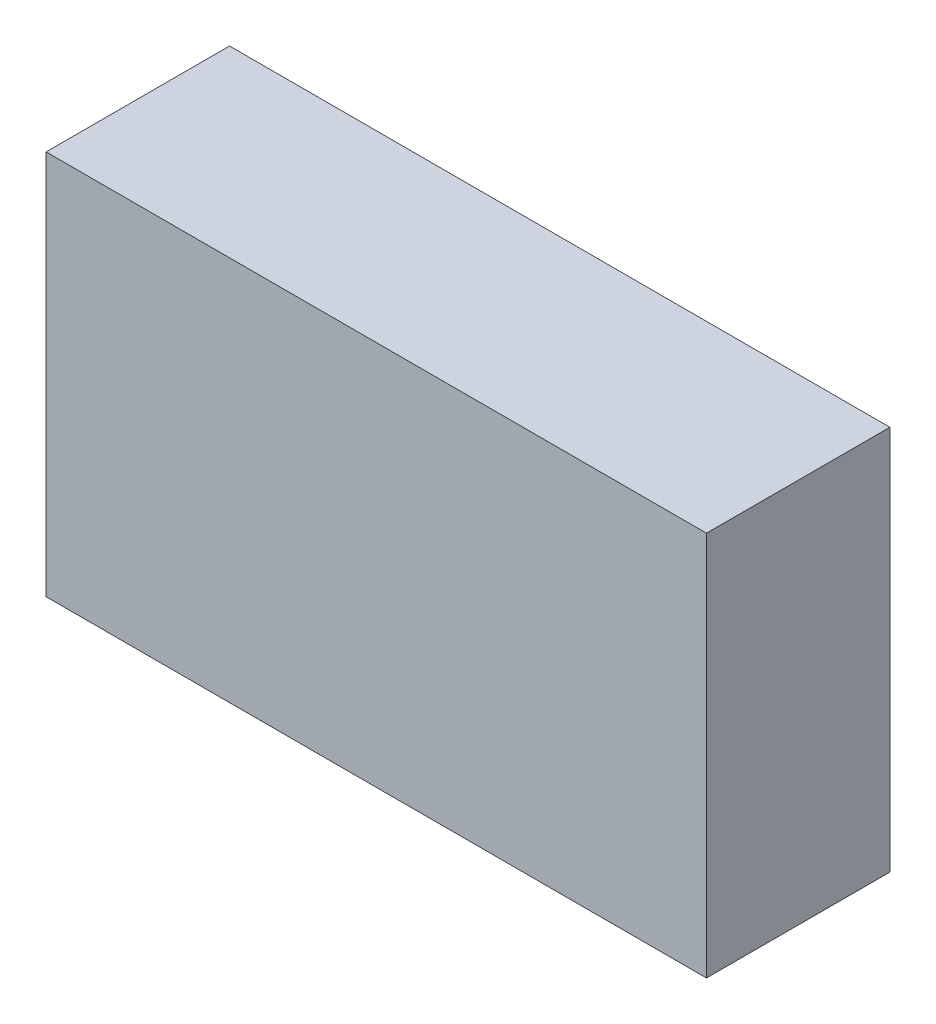
from build123d import *

# Parameters (mm, degrees)
SKETCH_1_W      = 36
SKETCH_1_H      = 21
SKETCH_1_R      = 1.25
SKETCH_1_R_2    = 1.3
SKETCH_1_R_3    = 1.35
EXTRUDE_1_DEPTH = 10


with BuildPart() as part:
    # 스케치1 → 보스-돌출1 (new body)
    with BuildSketch(Plane.XY):
        Rectangle(SKETCH_1_W, SKETCH_1_H)
        with Locations((-3.5, -8)):
            Circle(SKETCH_1_R, mode=Mode.SUBTRACT)
        with Locations((3.5, -8)):
            Circle(SKETCH_1_R, mode=Mode.SUBTRACT)
        with Locations((-12, 6)):
            Circle(SKETCH_1_R_2, mode=Mode.SUBTRACT)
        with Locations((12, 6)):
            Circle(SKETCH_1_R_2, mode=Mode.SUBTRACT)
        with Locations((12, -6)):
            Circle(SKETCH_1_R_2, mode=Mode.SUBTRACT)
        with Locations((-12, -6)):
            Circle(SKETCH_1_R_2, mode=Mode.SUBTRACT)
        with Locations((3.5, 8)):
            Circle(SKETCH_1_R_3, mode=Mode.SUBTRACT)
        with Locations((-3.5, 8)):
            Circle(SKETCH_1_R_3, mode=Mode.SUBTRACT)
        with Locations((12, -6)):
            Circle(SKETCH_1_R_2)
        with Locations((3.5, -8)):
            Circle(SKETCH_1_R)
        with Locations((-3.5, -8)):
            Circle(SKETCH_1_R)
        with Locations((-12, -6)):
            Circle(SKETCH_1_R_2)
        with Locations((-12, 6)):
            Circle(SKETCH_1_R_2)
        with Locations((-3.5, 8)):
            Circle(SKETCH_1_R_3)
        with Locations((3.5, 8)):
            Circle(SKETCH_1_R_3)
        with Locations((12, 6)):
            Circle(SKETCH_1_R_2)
    extrude(amount=EXTRUDE_1_DEPTH)


solid = part.part
